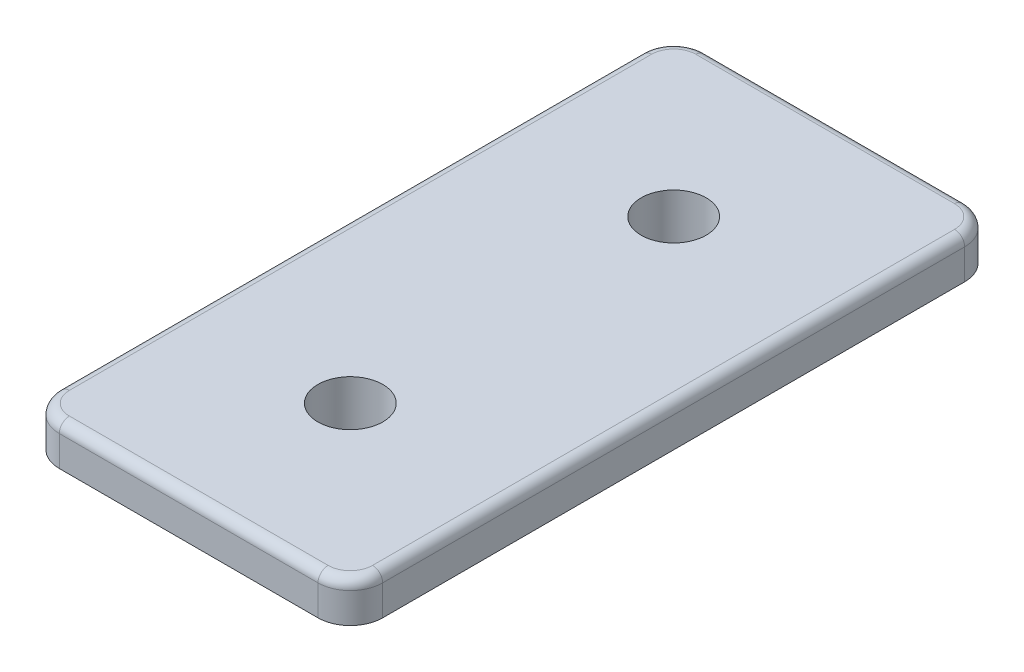
from build123d import *

# Parameters (mm, degrees)
SKETCH1_W           = 21.717
SKETCH1_H           = 47.117
BOSS_EXTRUDE1_DEPTH = 0.762
SKETCH2_W           = 25.4
SKETCH2_H           = 50.8
BOSS_EXTRUDE2_DEPTH = 3.175
SKETCH3_R           = 2.5527
CUT_EXTRUDE1_DEPTH  = 4.937
FILLET1_R           = 2.54
FILLET3_R           = 0.79375


with BuildPart() as part:
    # Sketch1 → Boss-Extrude1 (new body)
    with BuildSketch(Plane(origin=(0, 0, 0), x_dir=(1, 0, 0), z_dir=(0, 1, 0))):
        Rectangle(SKETCH1_W, SKETCH1_H)
    extrude(amount=BOSS_EXTRUDE1_DEPTH)

    # Sketch2 → Boss-Extrude2 (add)
    with BuildSketch(Plane(origin=(0, 0.762, 0), x_dir=(1, 0, 0), z_dir=(0, 1, 0))):
        Rectangle(SKETCH2_W, SKETCH2_H)
    extrude(amount=BOSS_EXTRUDE2_DEPTH)

    # Sketch3 → Cut-Extrude1 (cut, through all)
    with BuildSketch(Plane(origin=(0, 3.937, 0), x_dir=(1, 0, 0), z_dir=(0, 1, 0))):
        with Locations((0, 12.7)):
            Circle(SKETCH3_R)
        with Locations((0, -12.7)):
            Circle(SKETCH3_R)
    extrude(amount=-CUT_EXTRUDE1_DEPTH, mode=Mode.SUBTRACT)

    # Fillet1
    fillet1_edges = [part.edges().sort_by_distance(p)[0] for p in [
        (12.7, 2.3495, 25.4),
        (12.7, 2.3495, -25.4),
        (-12.7, 2.3495, -25.4),
        (-12.7, 2.3495, 25.4),
        (-10.8585, 0.381, -23.5585),
        (10.8585, 0.381, -23.5585),
        (10.8585, 0.381, 23.5585),
        (-10.8585, 0.381, 23.5585),
    ]]
    fillet(fillet1_edges, radius=FILLET1_R)

    # Fillet3
    fillet3_edges = [part.edges().sort_by_distance(p)[0] for p in [
        (0, 3.937, -25.4),
        (12.7, 3.937, 0),
        (-12.7, 3.937, 0),
        (0, 3.937, 25.4),
        (-11.956051224, 3.937, 24.656051224),
        (-11.956051224, 3.937, -24.656051224),
        (11.956051224, 3.937, 24.656051224),
        (11.956051224, 3.937, -24.656051224),
    ]]
    fillet(fillet3_edges, radius=FILLET3_R)


solid = part.part
